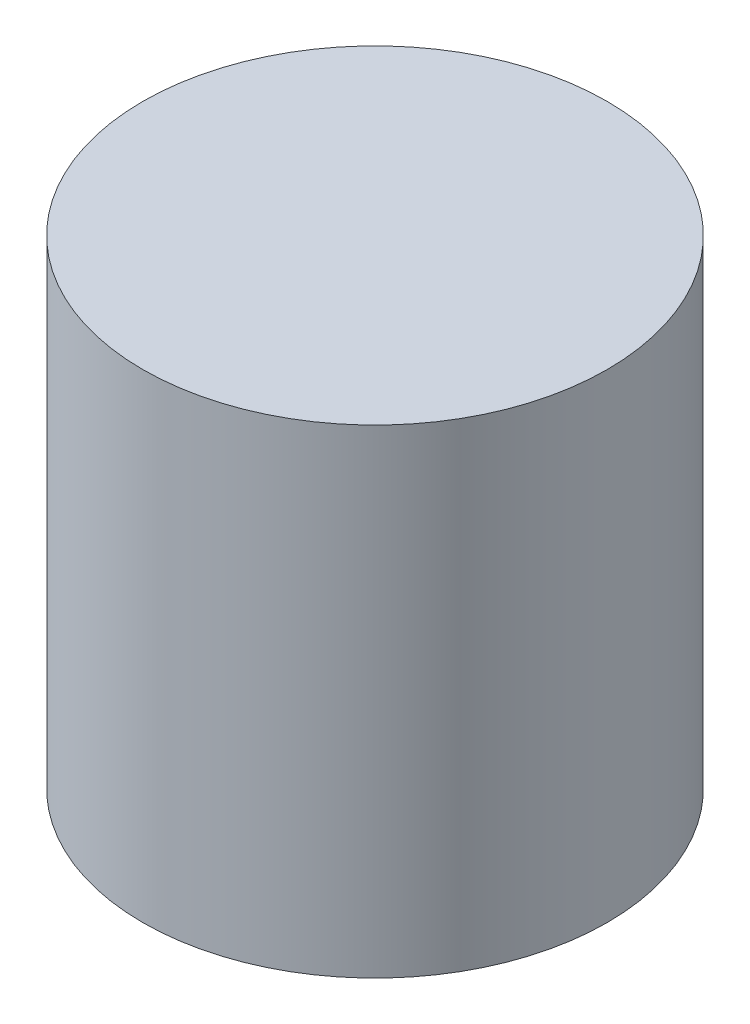
from build123d import *

# Parameters (mm, degrees)
SKETCH1_R           = 8
BOSS_EXTRUDE1_DEPTH = 16.5


with BuildPart() as part:
    # Sketch1 → Boss-Extrude1 (new body)
    with BuildSketch(Plane(origin=(0, 0, 0), x_dir=(1, 0, 0), z_dir=(0, 1, 0))):
        Circle(SKETCH1_R)
    extrude(amount=BOSS_EXTRUDE1_DEPTH)


solid = part.part
